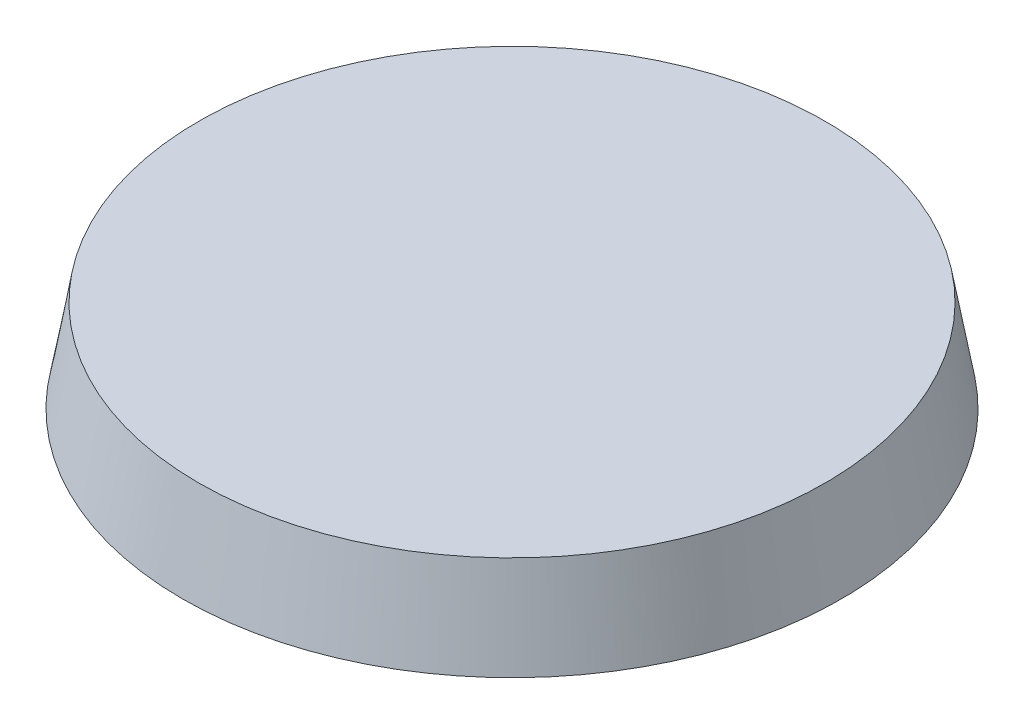
from build123d import *

# Parameters (mm, degrees)
SKETCH_1_R      = 12.5
EXTRUDE_1_DEPTH = 3.5
EXTRUDE_1_TAPER = 10


with BuildPart() as part:
    # Эскиз1 → Бобышка-Вытянуть1 (new body)
    with BuildSketch(Plane(origin=(0, 0, 0), x_dir=(1, 0, 0), z_dir=(0, 1, 0))):
        Circle(SKETCH_1_R)
    extrude(amount=EXTRUDE_1_DEPTH, taper=EXTRUDE_1_TAPER)


solid = part.part
